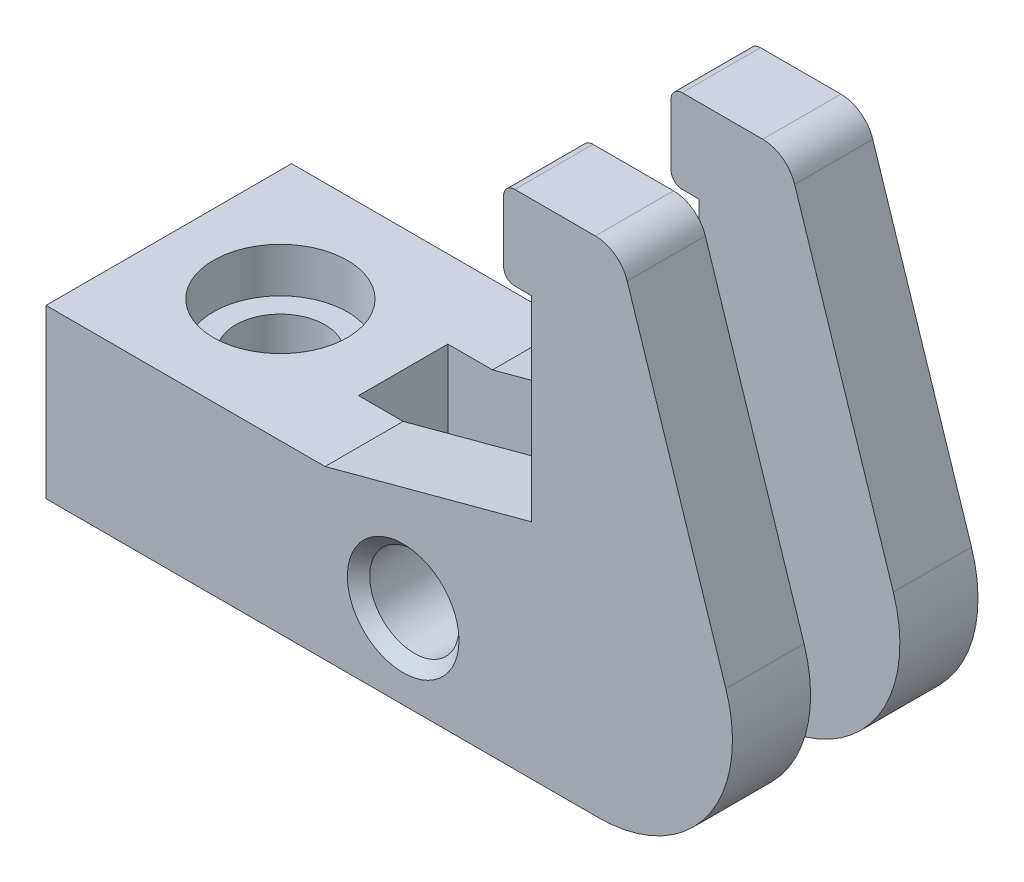
from build123d import *

# Parameters (mm, degrees)
ESTRUSIONE_ESTRUSIONE2_DEPTH  = 11
RACCORDO1_R                   = 3
SCHIZZO2_R                    = 4
TAGLIO_ESTRUSIONE1_DEPTH      = 70.305483189
SCHIZZO2_3_R                  = 6
SCHIZZO2_3_R_2                = 4
TAGLIO_ESTRUSIONE2_DEPTH      = 4
RACCORDO2_R                   = 1
TAGLIO_ESTRUSIONE4_DEPTH      = 77.995129716
TAGLIO_ESTRUSIONE4_DEPTH_BACK = 77.995129716
SCHIZZO3_W                    = 40.5
SCHIZZO3_H                    = 8
SCHIZZO4_R                    = 4
TAGLIO_ESTRUSIONE5_DEPTH      = 80.317400361
SMUSSO1_SIZE                  = 1


with BuildPart() as part:
    # Schizzo1 → Estrusione-Estrusione2 (new, symmetric)
    with BuildSketch(Plane.XY):
        with BuildLine():
            Line((0, 0), (0, 15))
            Line((0, 15), (25, 15))
            Line((25, 15), (43.5, 19.95706006))
            Line((43.5, 19.95706006), (43.5, 37.5))
            Line((43.5, 37.5), (41, 37.5))
            Line((41, 37.5), (41, 45))
            Line((41, 45), (51.395196715, 45))
            Line((51.395196715, 45), (60.912678196, 15.708203932))
            ThreePointArc((60.912678196, 15.708203932), (59.208203932, 4.946576972), (49.5, 0))
            Line((49.5, 0), (0, 0))
        make_face()
    extrude(amount=ESTRUSIONE_ESTRUSIONE2_DEPTH, both=True)

    # Raccordo1
    raccordo1_edges = [part.edges().sort_by_distance(p)[0] for p in [
        (51.395196715, 45, 0),
    ]]
    fillet(raccordo1_edges, radius=RACCORDO1_R)

    # Schizzo2 → Taglio-Estrusione1 (cut, through all)
    with BuildSketch(Plane(origin=(0, 15, 0), x_dir=(1, 0, 0), z_dir=(0, 1, 0))):
        with Locations((10, 0)):
            Circle(SCHIZZO2_R)
    extrude(amount=-TAGLIO_ESTRUSIONE1_DEPTH, mode=Mode.SUBTRACT)

    # Schizzo2_3 → Taglio-Estrusione2 (cut)
    with BuildSketch(Plane(origin=(0, 15, 0), x_dir=(1, 0, 0), z_dir=(0, 1, 0))):
        with Locations((10, 0)):
            Circle(SCHIZZO2_3_R)
        with Locations((10, 0)):
            Circle(SCHIZZO2_3_R_2, mode=Mode.SUBTRACT)
    extrude(amount=-TAGLIO_ESTRUSIONE2_DEPTH, mode=Mode.SUBTRACT)

    # Raccordo2
    raccordo2_edges = [part.edges().sort_by_distance(p)[0] for p in [
        (41, 45, 0),
        (41, 37.5, 0),
    ]]
    fillet(raccordo2_edges, radius=RACCORDO2_R)

    # Schizzo3 → Taglio-Estrusione4 (cut, two sides: drawn at the far end of the back side and taken through both)
    with BuildSketch(Plane(origin=(0, 0, 0), x_dir=(1, 0, 0), z_dir=(0, 1, 0)).offset(-TAGLIO_ESTRUSIONE4_DEPTH_BACK)):
        with Locations((41.25, 0)):
            Rectangle(SCHIZZO3_W, SCHIZZO3_H)
    extrude(amount=TAGLIO_ESTRUSIONE4_DEPTH + TAGLIO_ESTRUSIONE4_DEPTH_BACK, mode=Mode.SUBTRACT)

    # Schizzo4 → Taglio-Estrusione5 (cut, through all)
    with BuildSketch(Plane.XY.offset(11)):
        with Locations((32, 7.5)):
            Circle(SCHIZZO4_R)
    extrude(amount=-TAGLIO_ESTRUSIONE5_DEPTH, mode=Mode.SUBTRACT)

    # Smusso1
    smusso1_edges = [part.edges().sort_by_distance(p)[0] for p in [
        (28, 7.5, 11),
        (28, 7.5, -11),
    ]]
    chamfer(smusso1_edges, length=SMUSSO1_SIZE)


solid = part.part
